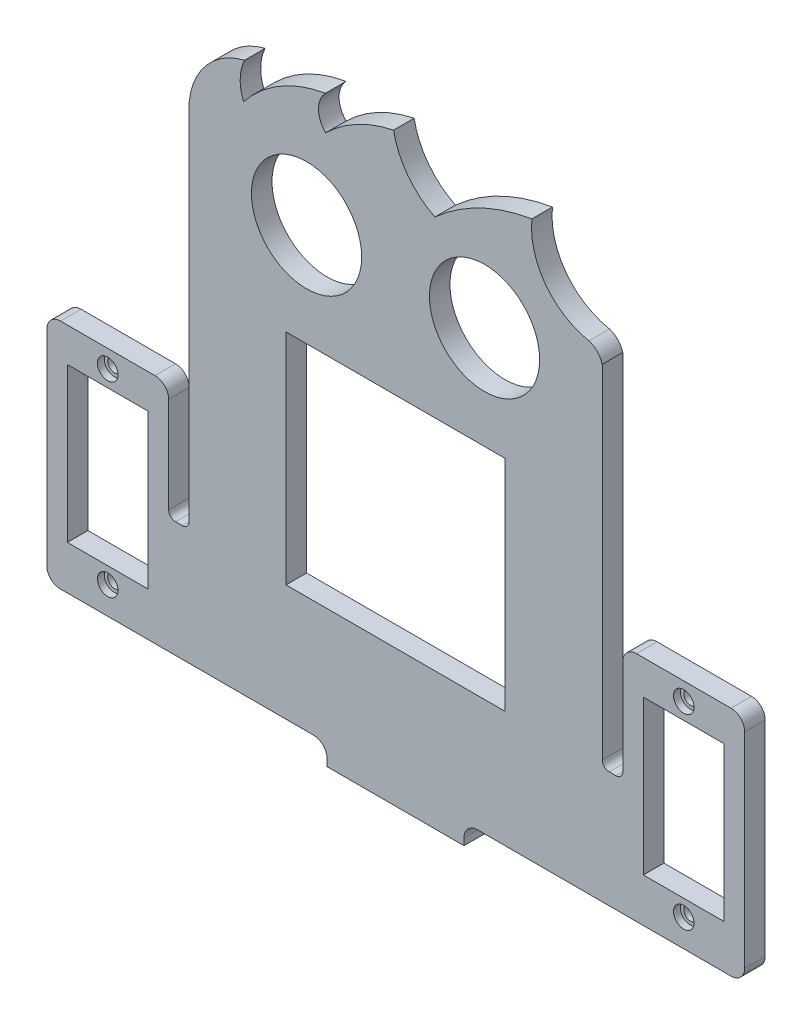
from build123d import *

# Parameters (mm, degrees)
MODEL_R                 = 8.05
MODEL_R_2               = 1
MODEL_W                 = 32
MODEL_H                 = 32
MODEL_W_2               = 11.8
MODEL_H_2               = 22.5
SALIENTE_EXTRUIR1_DEPTH = 3
CROQUIS2_W              = 19.999999999
CROQUIS2_H              = 3
SALIENTE_EXTRUIR2_DEPTH = 11
CROQUIS3_R              = 1.5
CORTAR_EXTRUIR1_DEPTH   = 3
REDONDEO1_R             = 2
CROQUIS4_R              = 2.25
CORTAR_EXTRUIR2_DEPTH   = 1
CROQUIS6_R              = 1.5
CORTAR_EXTRUIR4_DEPTH   = 1


with BuildPart() as part:
    # Model → Saliente-Extruir1 (new body)
    with BuildSketch(Plane.XY):
        with BuildLine():
            Line((68.698959582, -55.021016271), (68.698959582, -56.021017288))
            Line((68.698959582, -56.021017288), (48.698959583, -56.021017288))
            Line((48.698959583, -56.021017288), (48.698959583, -55.020994548))
            ThreePointArc((48.698959583, -55.020994548), (48.113181185, -53.606789026), (46.698982323, -53.020994548))
            Line((46.698982323, -53.020994548), (9.698959583, -53.020573857))
            ThreePointArc((9.698959583, -53.020573857), (8.324569809, -52.451282972), (7.755278924, -51.076893199))
            Line((7.755278924, -51.076893199), (7.755278924, -21.120997464))
            ThreePointArc((7.755278924, -21.120997464), (8.341065362, -19.706783901), (9.755278924, -19.120997464))
            Line((9.755278924, -19.120997464), (23.555278924, -19.120997464))
            ThreePointArc((23.555278924, -19.120997464), (24.969492487, -19.706783901), (25.555278924, -21.120997464))
            Line((25.555278924, -21.120997464), (25.555278924, -35.098945331))
            ThreePointArc((25.555278924, -35.098945331), (25.848172143, -35.806052112), (26.555278924, -36.098945331))
            Line((26.555278924, -36.098945331), (27.555278924, -36.098945331))
            ThreePointArc((27.555278924, -36.098945331), (28.262385705, -35.806052112), (28.555278924, -35.098945331))
            Line((28.555278924, -35.098945331), (28.555278924, 17.979002536))
            ThreePointArc((28.555278924, 17.979002536), (31.105578849, 23.945942388), (36.646410135, 27.323454721))
            ThreePointArc((36.646410135, 27.323454721), (36.00468524, 24.677778482), (36.499385848, 22.000712008))
            ThreePointArc((36.499385848, 22.000712008), (41.828182769, 26.639397126), (48.466982875, 29.055966887))
            ThreePointArc((48.466982875, 29.055966887), (47.442986911, 26.551218848), (48.490036744, 24.056020035))
            ThreePointArc((48.490036744, 24.056020035), (53.067544133, 27.431151144), (58.41559095, 29.365958406))
            ThreePointArc((58.41559095, 29.365958406), (60.493005652, 24.667283017), (64.452413363, 21.393708086))
            ThreePointArc((64.452413363, 21.393708086), (71.044296854, 25.835788254), (78.620547187, 28.241081393))
            ThreePointArc((78.620547187, 28.241081393), (80.583592254, 20.972839466), (86.965006165, 16.978037452))
            ThreePointArc((86.965006165, 16.978037452), (88.174666897, 16.217466641), (88.895278924, 14.983584414))
            Line((88.895278924, 14.983584414), (88.895278924, -35.070997464))
            ThreePointArc((88.895278924, -35.070997464), (89.188172143, -35.778104245), (89.895278924, -36.070997464))
            Line((89.895278924, -36.070997464), (90.898959582, -36.070997464))
            ThreePointArc((90.898959582, -36.070997464), (91.606066364, -35.778104245), (91.898959582, -35.070997464))
            Line((91.898959582, -35.070997464), (91.898959582, -21.120997464))
            ThreePointArc((91.898959582, -21.120997464), (92.48474602, -19.706783901), (93.898959582, -19.120997464))
            Line((93.898959582, -19.120997464), (107.698959583, -19.120997464))
            ThreePointArc((107.698959583, -19.120997464), (109.113173145, -19.706783901), (109.698959582, -21.120997464))
            Line((109.698959582, -21.120997464), (109.698959582, -51.020997464))
            ThreePointArc((109.698959582, -51.020997464), (109.113173145, -52.435211026), (107.698959583, -53.020997464))
            Line((107.698959583, -53.020997464), (70.698958566, -53.021016271))
            ThreePointArc((70.698958566, -53.021016271), (69.284745661, -53.606803068), (68.698959582, -55.021016271))
        make_face()
        with Locations((71.698959582, 10.979002536)):
            Circle(MODEL_R, mode=Mode.SUBTRACT)
        with Locations((45.698959583, 10.979002536)):
            Circle(MODEL_R, mode=Mode.SUBTRACT)
        with Locations((100.798959583, -21.720997464)):
            Circle(MODEL_R_2, mode=Mode.SUBTRACT)
        with Locations((100.798959583, -49.020997464)):
            Circle(MODEL_R_2, mode=Mode.SUBTRACT)
        with Locations((16.655278924, -49.020997464)):
            Circle(MODEL_R_2, mode=Mode.SUBTRACT)
        with Locations((16.655278924, -21.720997464)):
            Circle(MODEL_R_2, mode=Mode.SUBTRACT)
        with Locations((58.698959582, -20.020997464)):
            Rectangle(MODEL_W, MODEL_H, mode=Mode.SUBTRACT)
        with Locations((100.798959582, -35.370997464)):
            Rectangle(MODEL_W_2, MODEL_H_2, mode=Mode.SUBTRACT)
        with Locations((16.655278924, -35.370997464)):
            Rectangle(MODEL_W_2, MODEL_H_2, mode=Mode.SUBTRACT)
    extrude(amount=SALIENTE_EXTRUIR1_DEPTH)

    # Croquis2 → Saliente-Extruir2 (add)
    with BuildSketch(Plane.XY.offset(3)):
        with Locations((58.698959583, -54.521017288)):
            Rectangle(CROQUIS2_W, CROQUIS2_H)
    extrude(amount=-SALIENTE_EXTRUIR2_DEPTH)

    # Croquis3 → Cortar-Extruir1 (cut)
    with BuildSketch(Plane(origin=(0, -53.021017288, 0), x_dir=(1, 0, 0), z_dir=(0, 1, 0))):
        with Locations((52.698959583, 3.5)):
            Circle(CROQUIS3_R)
        with Locations((64.698959583, 3.5)):
            Circle(CROQUIS3_R)
    extrude(amount=-CORTAR_EXTRUIR1_DEPTH, mode=Mode.SUBTRACT)

    # Redondeo1
    redondeo1_edges = [part.edges().sort_by_distance(p)[0] for p in [
        (48.698959583, -54.521017288, -8),
        (68.698959582, -54.521017288, -8),
    ]]
    fillet(redondeo1_edges, radius=REDONDEO1_R)

    # Croquis4 → Cortar-Extruir2 (cut)
    with BuildSketch(Plane(origin=(0, -53.021017288, 0), x_dir=(1, 0, 0), z_dir=(0, 1, 0))):
        with Locations((52.698959583, 3.5)):
            Circle(CROQUIS4_R)
        with Locations((64.698959583, 3.5)):
            Circle(CROQUIS4_R)
    extrude(amount=-CORTAR_EXTRUIR2_DEPTH, mode=Mode.SUBTRACT)

    # Croquis6 → Cortar-Extruir4 (cut)
    with BuildSketch(Plane.XY.offset(3)):
        with Locations((16.655278924, -21.720997464)):
            Circle(CROQUIS6_R)
        with Locations((16.655278924, -49.020997464)):
            Circle(CROQUIS6_R)
        with Locations((100.798959583, -49.020997464)):
            Circle(CROQUIS6_R)
        with Locations((100.798959583, -21.720997464)):
            Circle(CROQUIS6_R)
    extrude(amount=-CORTAR_EXTRUIR4_DEPTH, mode=Mode.SUBTRACT)


solid = part.part
